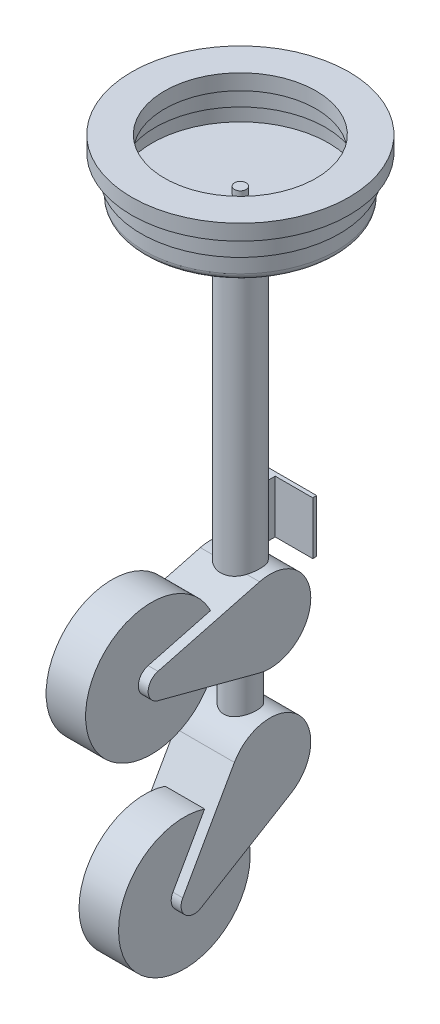
from build123d import *

# Parameters (mm, degrees)
SKETCH1_W                = 140
SKETCH1_H                = 80
BOSS_EXTRUDE1_DEPTH      = 6
SKETCH2_R                = 30
BOSS_EXTRUDE2_DEPTH      = 400
BOSS_EXTRUDE2_DEPTH_BACK = 70
SKETCH3_R                = 25
BOSS_EXTRUDE3_DEPTH      = 45
BOSS_EXTRUDE4_DEPTH      = 45
BOSS_EXTRUDE4_DEPTH_BACK = 45
SKETCH6_R                = 100
BOSS_EXTRUDE5_DEPTH      = 30
BOSS_EXTRUDE5_DEPTH_BACK = 30
SKETCH7_W                = 25.927573348
SKETCH7_H                = 80
BOSS_EXTRUDE6_DEPTH      = 12.945606
SKETCH9_R                = 25
BOSS_EXTRUDE7_DEPTH      = 189
BOSS_EXTRUDE8_DEPTH      = 45
BOSS_EXTRUDE8_DEPTH_BACK = 45
SKETCH11_R               = 100
BOSS_EXTRUDE9_DEPTH      = 30
BOSS_EXTRUDE9_DEPTH_BACK = 30


with BuildPart() as part:
    # Sketch1 → Boss-Extrude1 (new body)
    with BuildSketch(Plane.XY):
        Rectangle(SKETCH1_W, SKETCH1_H)
    extrude(amount=BOSS_EXTRUDE1_DEPTH)



with BuildPart() as body_2:
    # Sketch2 → Boss-Extrude2 (new body, two sides)
    with BuildSketch(Plane(origin=(0, 0, 0), x_dir=(1, 0, 0), z_dir=(0, 1, 0))) as boss_extrude2_sk:
        with Locations((0, -46)):
            Circle(SKETCH2_R)
    extrude(amount=BOSS_EXTRUDE2_DEPTH)
    extrude(boss_extrude2_sk.sketch, amount=-BOSS_EXTRUDE2_DEPTH_BACK)

    # Sketch3 → Boss-Extrude3 (add)
    with BuildSketch(Plane.XZ.offset(70)):
        with Locations((0, 46)):
            Circle(SKETCH3_R)
    extrude(amount=BOSS_EXTRUDE3_DEPTH)


with BuildPart() as body_3:
    # Sketch4 → Boss-Extrude4 (new body, two sides)
    with BuildSketch(Plane(origin=(0, 0, 0), x_dir=(0, 0, -1), z_dir=(1, 0, 0))) as boss_extrude4_sk:
        with BuildLine():
            Line((-61.781818182, -174.957770263), (-216.090909091, -134.341216214))
            ThreePointArc((-216.090909091, -134.341216214), (-231, -115), (-216.090909091, -95.658783786))
            Line((-216.090909091, -95.658783786), (-61.781818182, -55.042229737))
            ThreePointArc((-61.781818182, -55.042229737), (16, -115), (-61.781818182, -174.957770263))
        make_face()
    extrude(amount=BOSS_EXTRUDE4_DEPTH)
    extrude(boss_extrude4_sk.sketch, amount=-BOSS_EXTRUDE4_DEPTH_BACK)


with BuildPart() as body_4:
    # Sketch6 → Boss-Extrude5 (new body, two sides)
    with BuildSketch(Plane(origin=(0, 0, 0), x_dir=(0, 0, -1), z_dir=(1, 0, 0))) as boss_extrude5_sk:
        with Locations((-211, -115)):
            Circle(SKETCH6_R)
    extrude(amount=BOSS_EXTRUDE5_DEPTH)
    extrude(boss_extrude5_sk.sketch, amount=-BOSS_EXTRUDE5_DEPTH_BACK)


with BuildPart() as part_1:
    add(part.part)

    add(body_2.part)  # Boss-Extrude6 merges body 2
    # Sketch7 → Boss-Extrude6 (add)
    with BuildSketch(Plane.XY.offset(6)):
        Rectangle(SKETCH7_W, SKETCH7_H)
    extrude(amount=BOSS_EXTRUDE6_DEPTH)

    # Sketch8 → Revolve1 (revolve)
    with BuildSketch(Plane(origin=(0, 0, 0), x_dir=(0, 0, -1), z_dir=(1, 0, 0))):
        with BuildLine():
            Line((-46, 400), (-46, 435))
            Line((-46, 435), (-54.823317896, 435))
            Line((-54.823317896, 435), (-54.823317896, 424.802746782))
            Line((-54.823317896, 424.802746782), (-180, 424.802746782))
            Line((-180, 424.802746782), (-180, 447.802746782))
            Line((-180, 447.802746782), (-175.193885925, 447.802746782))
            Line((-175.193885925, 447.802746782), (-175.193885925, 479.193114191))
            Line((-175.193885925, 479.193114191), (-161, 479.193114191))
            Line((-161, 479.193114191), (-161, 502.802746782))
            Line((-161, 502.802746782), (-211, 502.802746782))
            Line((-211, 502.802746782), (-211, 479.193114191))
            Line((-211, 479.193114191), (-196.806114075, 479.193114191))
            Line((-196.806114075, 479.193114191), (-196.806114075, 447.802746782))
            Line((-196.806114075, 447.802746782), (-192, 447.802746782))
            Line((-192, 447.802746782), (-192, 422.802746782))
            ThreePointArc((-192, 422.802746782), (-189.071067812, 415.731678971), (-182, 412.802746782))
            Line((-182, 412.802746782), (-54.823317896, 412.802746782))
            Line((-54.823317896, 412.802746782), (-54.823317896, 400))
            Line((-54.823317896, 400), (-46, 400))
        make_face()
    revolve(axis=Axis((0, 400, 46), (0, 1, 0)))


with BuildPart() as body_4_2:
    # Sketch9 → Boss-Extrude7 (new body)
    with BuildSketch(Plane.XZ.offset(115)):
        with Locations((0, 46)):
            Circle(SKETCH9_R)
    extrude(amount=BOSS_EXTRUDE7_DEPTH)

    # Sketch10 → Boss-Extrude8 (add, two sides)
    with BuildSketch(Plane(origin=(0, 0, 0), x_dir=(0, 0, -1), z_dir=(1, 0, 0))) as boss_extrude8_sk:
        with BuildLine():
            Line((-178.417806727, -412.492047919), (-99.995200853, -273.528401997))
            ThreePointArc((-99.995200853, -273.528401997), (-2.787878788, -259.539764054), (-14.003697219, -357.105899939))
            Line((-14.003697219, -357.105899939), (-150.678612006, -439.452531126))
            ThreePointArc((-150.678612006, -439.452531126), (-174.939393939, -436.663607257), (-178.417806727, -412.492047919))
        make_face()
    extrude(amount=BOSS_EXTRUDE8_DEPTH)
    extrude(boss_extrude8_sk.sketch, amount=-BOSS_EXTRUDE8_DEPTH_BACK)

    # Sketch11 → Boss-Extrude9 (add, two sides)
    with BuildSketch(Plane(origin=(0, 0, 0), x_dir=(0, 0, -1), z_dir=(1, 0, 0))) as boss_extrude9_sk:
        with Locations((-161, -422.321595662)):
            Circle(SKETCH11_R)
    extrude(amount=BOSS_EXTRUDE9_DEPTH)
    extrude(boss_extrude9_sk.sketch, amount=-BOSS_EXTRUDE9_DEPTH_BACK)


solid = Compound([body_3.part, body_4.part, part_1.part, body_4_2.part])
